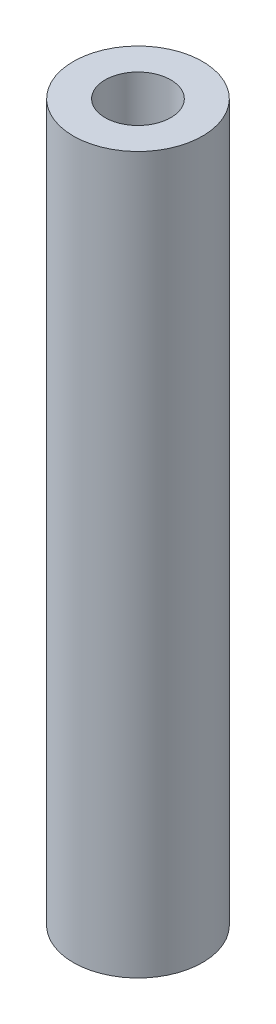
from build123d import *

# Parameters (mm, degrees)
ESBO_O2_R                = 3.25
RESSALTO_EXTRUS_O1_DEPTH = 18


with BuildPart() as part:
    # Esboço2 → Ressalto-extrusão1 (new body, symmetric)
    with BuildSketch(Plane(origin=(0, 0, 0), x_dir=(1, 0, 0), z_dir=(0, 1, 0))):
        Circle(ESBO_O2_R)
    extrude(amount=RESSALTO_EXTRUS_O1_DEPTH, both=True)

    # Esboço4 → Furo roscado de M41 (revolve, cut)
    with BuildSketch(Plane(origin=(0, 18, 0), x_dir=(0, 0, 1), z_dir=(1, 0, 0))):
        Polygon((0, 0), (0, 36), (2.025, 36), (1.65, 35.625), (1.65, 0), align=None)
    revolve(axis=Axis((0, 24.35, 0), (0, -1, 0)), mode=Mode.SUBTRACT)


solid = part.part
